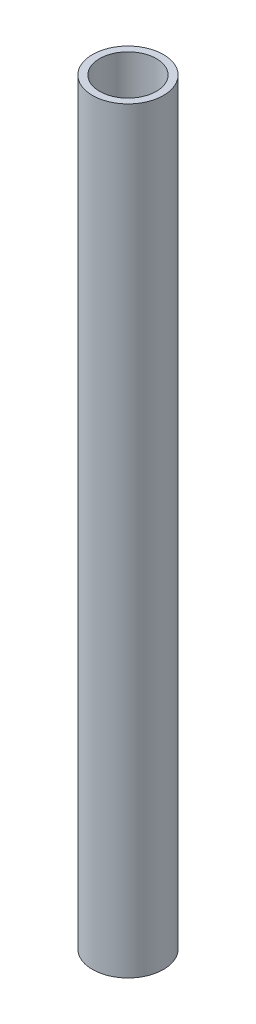
from build123d import *

# Parameters (mm, degrees)
SKETCH1_R           = 4.7625
SKETCH1_R_2         = 3.81
BOSS_EXTRUDE1_DEPTH = 101.6


with BuildPart() as part:
    # Sketch1 → Boss-Extrude1 (new body)
    with BuildSketch(Plane(origin=(0, 0, 0), x_dir=(1, 0, 0), z_dir=(0, 1, 0))):
        Circle(SKETCH1_R)
        Circle(SKETCH1_R_2, mode=Mode.SUBTRACT)
    extrude(amount=BOSS_EXTRUDE1_DEPTH)


solid = part.part
